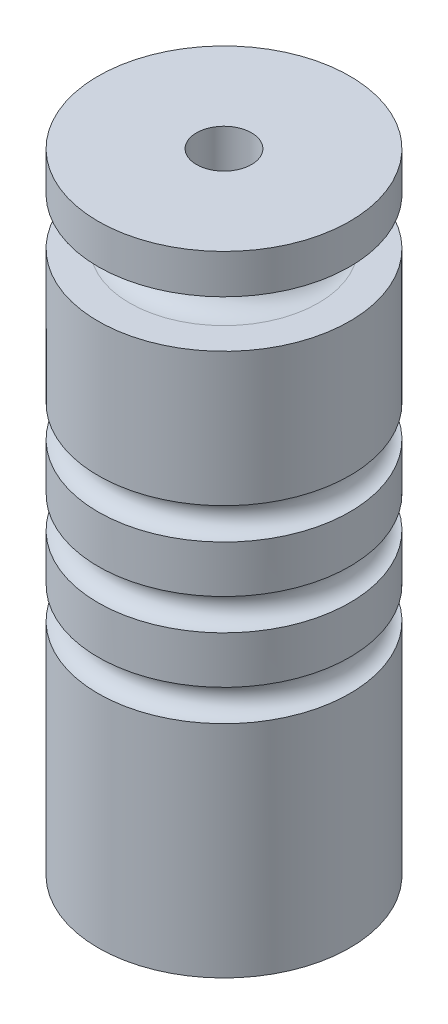
from build123d import *

# Parameters (mm, degrees)
SKETCH1_R      = 8
EXTRUDE1_DEPTH = 40
SKETCH2_R      = 1.75
EXTRUDE2_DEPTH = 40
SKETCH3_R      = 4
EXTRUDE3_DEPTH = 6.35
SKETCH4_R      = 1
SKETCH9_W      = 2.5
SKETCH9_H      = 3
SKETCH10_R     = 1.5


with BuildPart() as part:
    # Sketch1 → Extrude1 (new body)
    with BuildSketch(Plane(origin=(0, 0, 0), x_dir=(1, 0, 0), z_dir=(0, 1, 0))):
        Circle(SKETCH1_R)
    extrude(amount=EXTRUDE1_DEPTH)

    # Sketch2 → Extrude2 (cut)
    with BuildSketch(Plane(origin=(0, 40, 0), x_dir=(-1, 0, 0), z_dir=(0, 1, 0))):
        Circle(SKETCH2_R)
    extrude(amount=-EXTRUDE2_DEPTH, mode=Mode.SUBTRACT)

    # Sketch3 → Extrude3 (cut)
    with BuildSketch(Plane.XZ):
        Circle(SKETCH3_R)
    extrude(amount=-EXTRUDE3_DEPTH, mode=Mode.SUBTRACT)

    # Cut-Sweep1: sweep along a path in Sketch6
    with BuildLine(Plane(origin=(0, 15, 0), x_dir=(-1, 0, 0), z_dir=(0, 1, 0))) as cut_sweep1_path:
        CenterArc((0, 0), 8, 0, 360)
    # Sketch4 → Cut-Sweep1 (sweep, cut)
    with BuildSketch(Plane.XY):
        with Locations((8, 20)):
            Circle(SKETCH4_R)
        with Locations((8, 25)):
            Circle(SKETCH4_R)
        with Locations((8, 15)):
            Circle(SKETCH4_R)
    sweep(path=cut_sweep1_path.line, mode=Mode.SUBTRACT)

    # Cut-Sweep3: sweep along a path in Sketch8
    with BuildLine(Plane(origin=(0, 36, 0), x_dir=(-1, 0, 0), z_dir=(0, 1, 0))) as cut_sweep3_path:
        CenterArc((0, 0), 6, 0, 360)
    # Sketch9 → Cut-Sweep3 (sweep, cut)
    with BuildSketch(Plane.XY):
        with Locations((7.25, 36)):
            Rectangle(SKETCH9_W, SKETCH9_H)
    sweep(path=cut_sweep3_path.line, mode=Mode.SUBTRACT)

    # Cut-Sweep4: sweep along a path in Sketch11
    with BuildLine(Plane(origin=(0, 36, 0), x_dir=(-1, 0, 0), z_dir=(0, 1, 0))) as cut_sweep4_path:
        CenterArc((0, 0), 6, 0, 360)
    # Sketch10 → Cut-Sweep4 (sweep, cut)
    with BuildSketch(Plane.XY):
        with Locations((6, 36)):
            Circle(SKETCH10_R)
    sweep(path=cut_sweep4_path.line, mode=Mode.SUBTRACT)


solid = part.part
